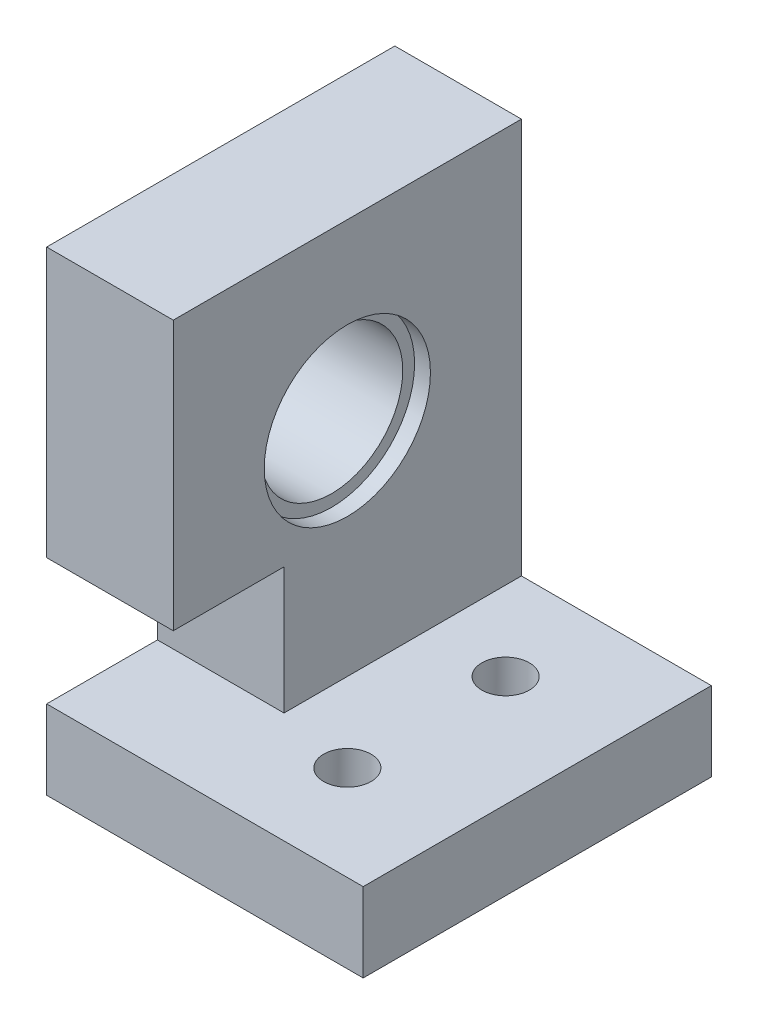
from build123d import *

# Parameters (mm, degrees)
SKETCH_1_W               = 40
SKETCH_1_H               = 23
SKETCH_1_R               = 4.5
EXTRUDE_1_DEPTH          = 8
SKETCH_2_R               = 5.25
CUT_EXTRUDE_1_DEPTH      = 1
CUT_EXTRUDE_2_DEPTH      = 9
SKETCH_5_R               = 5.25
CUT_EXTRUDE_3_DEPTH      = 1
SKETCH_6_W               = 22
SKETCH_6_H               = 5
EXTRUDE_3_DEPTH          = 6
SKETCH_7_W               = 11
SKETCH_7_H               = 4
EXTRUDE_4_DEPTH          = 4
EXTRUDE_6_DEPTH          = 3
SKETCH_12_W              = 8
SKETCH_12_H              = 15
EXTRUDE_7_DEPTH          = 13
SKETCH_13_W              = 22
SKETCH_13_H              = 5
EXTRUDE_8_DEPTH          = 10
SKETCH_14_W              = 6
SKETCH_14_H              = 22
CUT_EXTRUDE_9_DEPTH      = 13
CUT_EXTRUDE_9_DEPTH_BACK = 10
SKETCH_15_R              = 1.5
CUT_EXTRUDE_10_DEPTH     = 6
CUT_EXTRUDE_11_DEPTH     = 2.5
SKETCH_17_W              = 22
SKETCH_17_H              = 5
EXTRUDE_9_DEPTH          = 2
SKETCH_18_W              = 8
SKETCH_18_H              = 5
EXTRUDE_10_DEPTH         = 7


with BuildPart() as part:
    # 草图1 → 凸台-拉伸1 (new body)
    with BuildSketch(Plane(origin=(0, 0, 0), x_dir=(0, 0, -1), z_dir=(1, 0, 0))):
        with Locations((9, 5.5)):
            Rectangle(SKETCH_1_W, SKETCH_1_H)
        Circle(SKETCH_1_R, mode=Mode.SUBTRACT)
        with Locations((18, 6)):
            Circle(SKETCH_1_R, mode=Mode.SUBTRACT)
    extrude(amount=EXTRUDE_1_DEPTH)

    # 草图2 → 切除-拉伸1 (cut)
    with BuildSketch(Plane.ZY):
        with Locations((-18, 6)):
            Circle(SKETCH_2_R)
        Circle(SKETCH_2_R)
    extrude(amount=-CUT_EXTRUDE_1_DEPTH, mode=Mode.SUBTRACT)

    # 草图3 → 切除-拉伸2 (cut, through all)
    with BuildSketch(Plane(origin=(8, 0, 0), x_dir=(0, 0, -1), z_dir=(1, 0, 0))):
        Polygon((29, 17), (11, 17), (-11, 17), (-11, 11), (11, 11), (11, -6), (29, -6), align=None)
    extrude(amount=-CUT_EXTRUDE_2_DEPTH, mode=Mode.SUBTRACT)

    # 草图5 → 切除-拉伸3 (cut)
    with BuildSketch(Plane(origin=(8, 0, 0), x_dir=(0, 0, -1), z_dir=(1, 0, 0))):
        Circle(SKETCH_5_R)
    extrude(amount=-CUT_EXTRUDE_3_DEPTH, mode=Mode.SUBTRACT)

    # 草图6 → 凸台-拉伸3 (add)
    with BuildSketch(Plane(origin=(8, 0, 0), x_dir=(0, 0, -1), z_dir=(1, 0, 0))):
        with Locations((0, -3.5)):
            Rectangle(SKETCH_6_W, SKETCH_6_H)
    extrude(amount=EXTRUDE_3_DEPTH)

    # 草图7 → 凸台-拉伸4 (add)
    with BuildSketch(Plane.XZ.offset(6)):
        with Locations((8.5, -9)):
            Rectangle(SKETCH_7_W, SKETCH_7_H)
    extrude(amount=EXTRUDE_4_DEPTH)

    # 草图11 → 凸台-拉伸6 (add)
    with BuildSketch(Plane(origin=(0, 0, -11), x_dir=(-1, 0, 0), z_dir=(0, 0, -1))):
        Polygon((-8, -1), (-8, 11), (-14, -1), align=None)
    extrude(amount=-EXTRUDE_6_DEPTH)

    # 草图12 → 凸台-拉伸7 (add)
    with BuildSketch(Plane.XZ.offset(6)):
        with Locations((4, -3.5)):
            Rectangle(SKETCH_12_W, SKETCH_12_H)
    extrude(amount=EXTRUDE_7_DEPTH)

    # 草图13 → 凸台-拉伸8 (add)
    with BuildSketch(Plane(origin=(8, 0, 0), x_dir=(0, 0, -1), z_dir=(1, 0, 0))):
        with Locations((0, -16.5)):
            Rectangle(SKETCH_13_W, SKETCH_13_H)
    extrude(amount=EXTRUDE_8_DEPTH)

    # 草图14 → 切除-拉伸9 (cut, two sides)
    with BuildSketch(Plane(origin=(0, -1, 0), x_dir=(1, 0, 0), z_dir=(0, 1, 0))) as cut_extrude_9_sk:
        with Locations((11, 0)):
            Rectangle(SKETCH_14_W, SKETCH_14_H)
    extrude(amount=CUT_EXTRUDE_9_DEPTH, mode=Mode.SUBTRACT)
    extrude(cut_extrude_9_sk.sketch, amount=-CUT_EXTRUDE_9_DEPTH_BACK, mode=Mode.SUBTRACT)

    # 草图15 → 切除-拉伸10 (cut, through all)
    with BuildSketch(Plane(origin=(0, -14, 0), x_dir=(-1, 0, 0), z_dir=(0, 1, 0))):
        with Locations((-13, -5)):
            Circle(SKETCH_15_R)
        with Locations((-13, 5)):
            Circle(SKETCH_15_R)
    extrude(amount=-CUT_EXTRUDE_10_DEPTH, mode=Mode.SUBTRACT)

    # 草图16 → 切除-拉伸11 (cut)
    with BuildSketch(Plane.XZ.offset(19)):
        Polygon((16.204293994, 5), (14.602146997, 7.775), (11.397853003, 7.775), (9.795706006, 5), (11.397853003, 2.225), (14.602146997, 2.225), align=None)
        Polygon((16.204293994, -5), (14.602146997, -2.225), (11.397853003, -2.225), (9.795706006, -5), (11.397853003, -7.775), (14.602146997, -7.775), align=None)
    extrude(amount=-CUT_EXTRUDE_11_DEPTH, mode=Mode.SUBTRACT)

    # 草图17 → 凸台-拉伸9 (add)
    with BuildSketch(Plane(origin=(18, 0, 0), x_dir=(0, 0, -1), z_dir=(1, 0, 0))):
        with Locations((0, -16.5)):
            Rectangle(SKETCH_17_W, SKETCH_17_H)
    extrude(amount=EXTRUDE_9_DEPTH)

    # 草图18 → 凸台-拉伸10 (add, through all)
    with BuildSketch(Plane.XY.offset(4)):
        with Locations((4, -16.5)):
            Rectangle(SKETCH_18_W, SKETCH_18_H)
    extrude(amount=EXTRUDE_10_DEPTH)


solid = part.part
